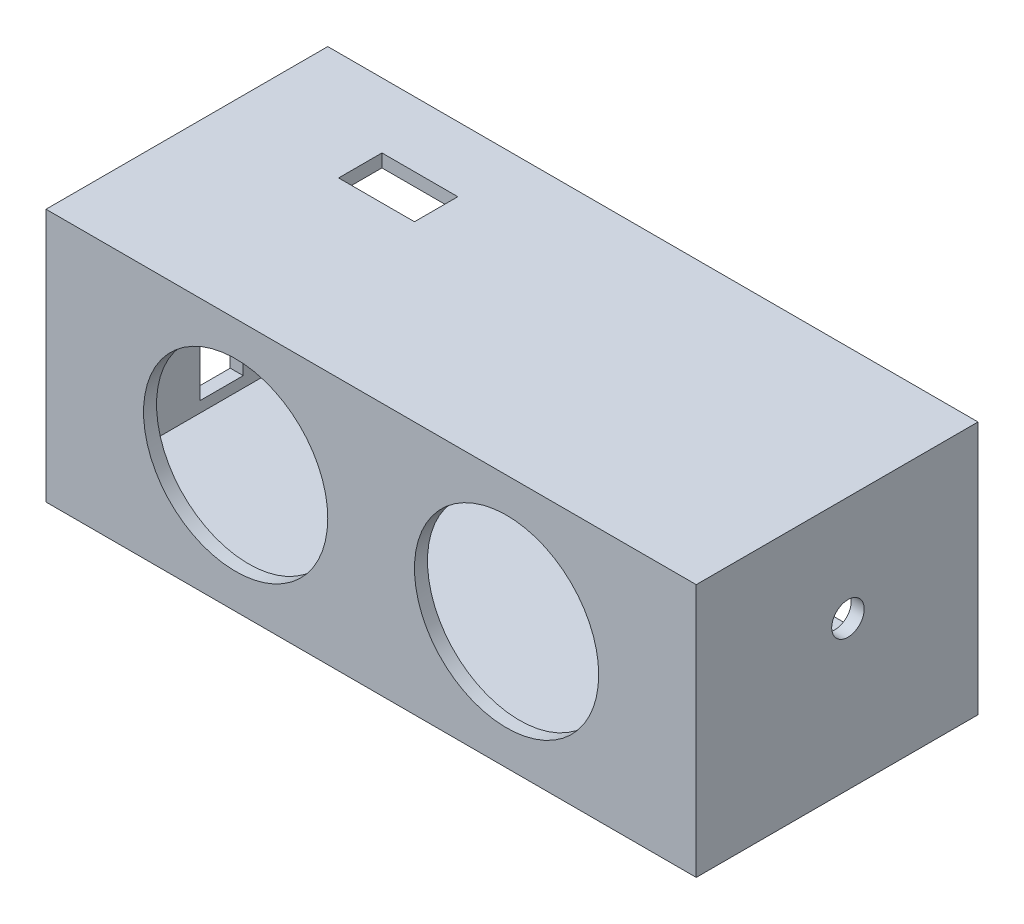
from build123d import *

# Parameters (mm, degrees)
F_3DSKETCH1_R       = 8.5
BOSS_EXTRUDE3_DEPTH = 1.2
SKETCH3_W           = 60
SKETCH3_H           = 23.4
SKETCH3_W_2         = 57.6
SKETCH3_H_2         = 21
BOSS_EXTRUDE4_DEPTH = 26
SKETCH6_W           = 3
SKETCH6_H           = 8
CUT_EXTRUDE1_DEPTH  = 4
SKETCH7_W           = 7
SKETCH7_H           = 4
CUT_EXTRUDE2_DEPTH  = 4
CUT_EXTRUDE4_DEPTH  = 4
SKETCH10_W          = 4
SKETCH10_H          = 4.5
SKETCH10_H_2        = 9.5
CUT_EXTRUDE5_DEPTH  = 4


with BuildPart() as part:
    # 3DSketch1 → Boss-Extrude3 (new body)
    with BuildSketch(Plane(origin=(-25.740687228, -9.071236551, 0), x_dir=(0.9316545551067793, 0.3633452764916439, 0), z_dir=(0, 0, -1))):
        Polygon((0, 0), (55.899273306, 21.800716589), (64.401552776, 0), (8.50227947, -21.800716589), align=None)
        with Locations(Location((20.555094449, -4.541815956, 0), (0, 0, 21.305783618))):
            Circle(F_3DSKETCH1_R, mode=Mode.SUBTRACT)
        with Locations(Location((43.846458327, 4.541815956, 0), (0, 0, 21.305783618))):
            Circle(F_3DSKETCH1_R, mode=Mode.SUBTRACT)
    extrude(amount=BOSS_EXTRUDE3_DEPTH)

    # Sketch3 → Boss-Extrude4 (add)
    with BuildSketch(Plane.XY):
        with Locations((4.259312772, 2.628763449)):
            Rectangle(SKETCH3_W, SKETCH3_H)
        with Locations((4.259312772, 2.628763449)):
            Rectangle(SKETCH3_W_2, SKETCH3_H_2, mode=Mode.SUBTRACT)
    extrude(amount=-BOSS_EXTRUDE4_DEPTH)

    # Sketch6 → Cut-Extrude1 (cut)
    with BuildSketch(Plane.XZ.offset(9.071236551)):
        with Locations((22.059312772, -13.2)):
            Rectangle(SKETCH6_W, SKETCH6_H)
    extrude(amount=-CUT_EXTRUDE1_DEPTH, mode=Mode.SUBTRACT)

    # Sketch7 → Cut-Extrude2 (cut)
    with BuildSketch(Plane(origin=(0, 14.328763449, 0), x_dir=(1, 0, 0), z_dir=(0, 1, 0))):
        with Locations((-11.240687228, 18)):
            Rectangle(SKETCH7_W, SKETCH7_H)
    extrude(amount=-CUT_EXTRUDE2_DEPTH, mode=Mode.SUBTRACT)

    # Sketch9 → Cut-Extrude4 (cut)
    with BuildSketch(Plane(origin=(34.259312772, 0, 0), x_dir=(0, 0, -1), z_dir=(1, 0, 0))):
        with BuildLine():
            Line((12.5, 4.628763449), (14, 4.628763449))
            Line((14, 4.628763449), (15.5, 4.628763449))
            ThreePointArc((15.5, 4.628763449), (14, 6.128763449), (12.5, 4.628763449))
        make_face()
        with BuildLine():
            Line((15.5, 4.628763449), (14, 4.628763449))
            Line((14, 4.628763449), (12.5, 4.628763449))
            ThreePointArc((12.5, 4.628763449), (14, 3.128763449), (15.5, 4.628763449))
        make_face()
    extrude(amount=-CUT_EXTRUDE4_DEPTH, mode=Mode.SUBTRACT)

    # Sketch10 → Cut-Extrude5 (cut)
    with BuildSketch(Plane.ZY.offset(25.740687228)):
        with Locations((-15, 4.878763449)):
            Rectangle(SKETCH10_W, SKETCH10_H)
        with Locations((-15, -2.121236551)):
            Rectangle(SKETCH10_W, SKETCH10_H_2)
    extrude(amount=-CUT_EXTRUDE5_DEPTH, mode=Mode.SUBTRACT)


solid = part.part
